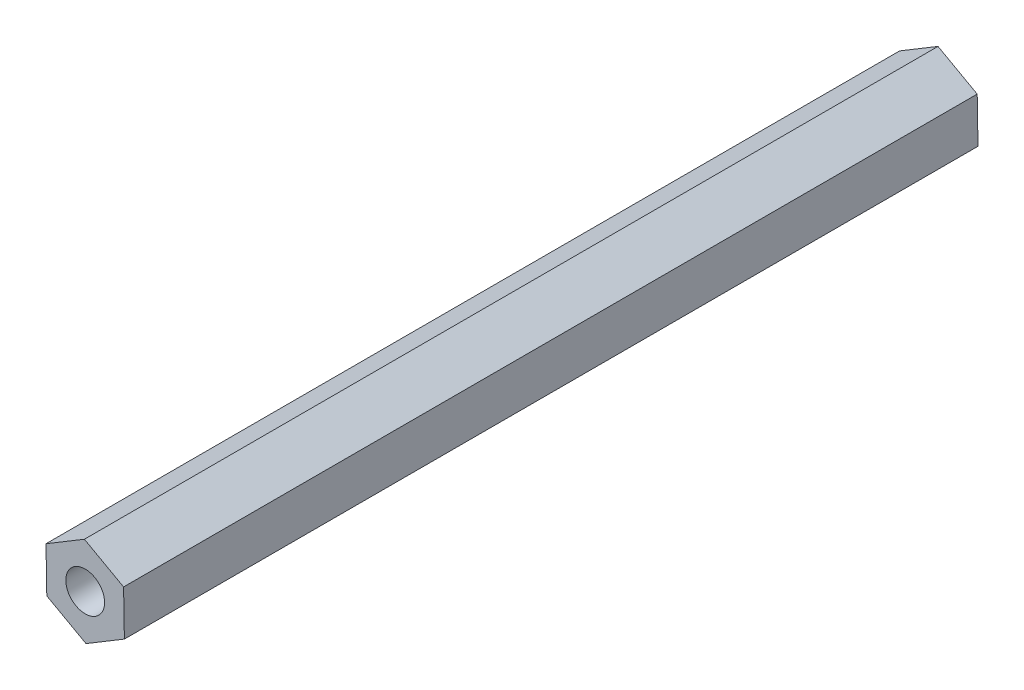
from build123d import *

# Parameters (mm, degrees)
BOSS_EXTRUDE1_DEPTH      = 69.85
BOSS_EXTRUDE1_DEPTH_BACK = 69.85
SKETCH1_R                = 3.175


with BuildPart() as part:
    # Sketch1 → Boss-Extrude1 (new, two sides: drawn at the far end of the back side and taken through both)
    with BuildSketch(Plane.XY.offset(-BOSS_EXTRUDE1_DEPTH_BACK)):
        Polygon((6.284319593, 3.777652789), (-0.129383485, 7.331206807), (-6.413703078, 3.553554018), (-6.284319593, -3.777652789), (0.129383485, -7.331206807), (6.413703078, -3.553554018), align=None)
        Circle(SKETCH1_R, mode=Mode.SUBTRACT)
    extrude(amount=BOSS_EXTRUDE1_DEPTH + BOSS_EXTRUDE1_DEPTH_BACK)


solid = part.part
